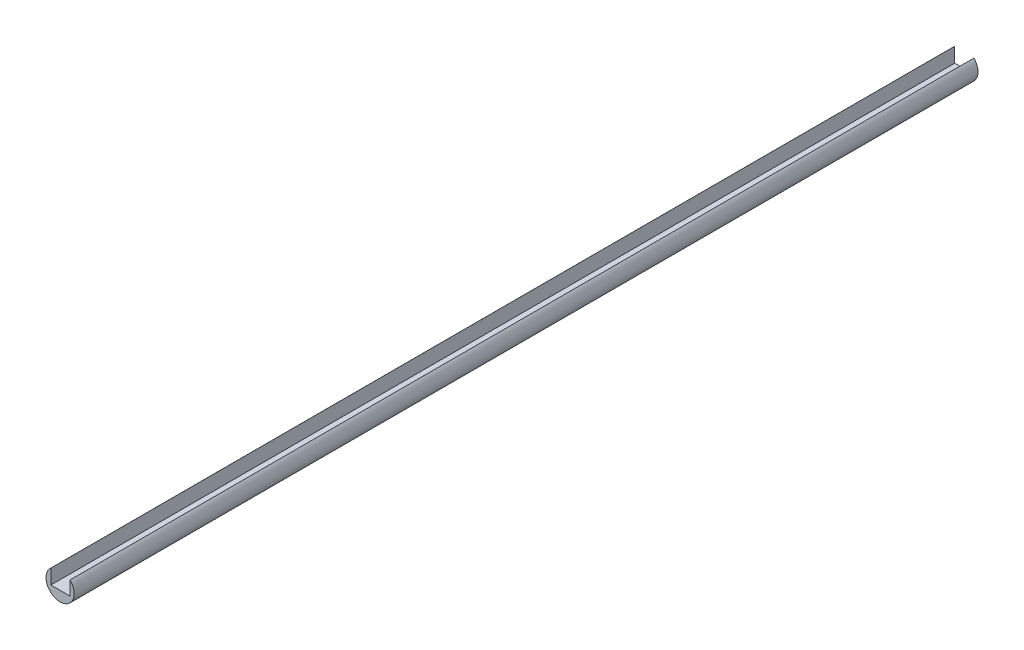
from build123d import *

# Parameters (mm, degrees)
SKETCH1_R           = 9.343454664
BOSS_EXTRUDE1_DEPTH = 600
CUT_EXTRUDE1_DEPTH  = 601


with BuildPart() as part:
    # Sketch1 → Boss-Extrude1 (new body)
    with BuildSketch(Plane.XY):
        with Locations((-85.814280173, -49.544897758)):
            Circle(SKETCH1_R)
    extrude(amount=BOSS_EXTRUDE1_DEPTH)

    # Sketch2 → Cut-Extrude1 (cut, through all)
    with BuildSketch(Plane.XY.offset(600)):
        with BuildLine():
            Line((-91.922148369, -42.474247777), (-91.922148369, -52.234040049))
            Line((-91.922148369, -52.234040049), (-79.199042479, -52.234040049))
            Line((-79.199042479, -52.234040049), (-79.199042479, -42.946505885))
            ThreePointArc((-79.199042479, -42.946505885), (-85.467707119, -40.207872955), (-91.922148369, -42.474247777))
        make_face()
    extrude(amount=-CUT_EXTRUDE1_DEPTH, mode=Mode.SUBTRACT)


solid = part.part
